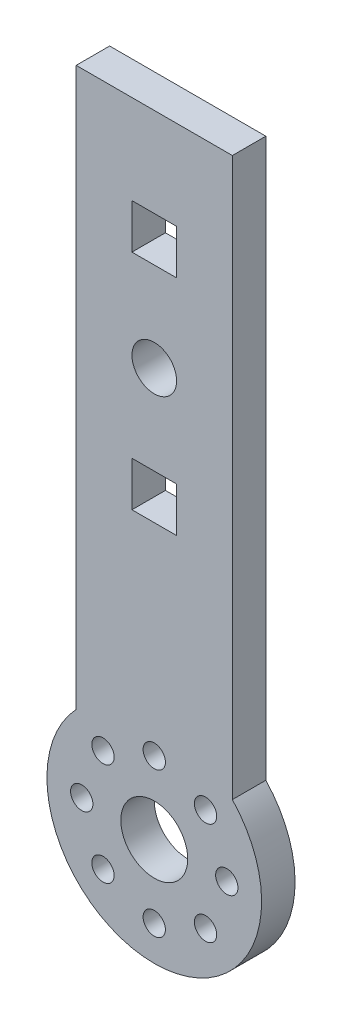
from build123d import *

# Parameters (mm, degrees)
SKETCH_1_W               = 14
SKETCH_1_H               = 13.200286042
EXTRUDE_1_DEPTH          = 3
SKETCH_3_OUTSIDE_W       = 35.048
SKETCH_3_OUTSIDE_H       = 82.027
CUT_EXTRUDE_2_DEPTH      = 3
SKETCH_4_R               = 3
CUT_EXTRUDE_3_DEPTH      = 10
SKETCH_5_R               = 1
CUT_EXTRUDE_4_DEPTH      = 10
SKETCH_6_W               = 4
SKETCH_6_H               = 4
EXTRUDE_3_DEPTH          = 3
CUT_EXTRUDE_5_DEPTH      = 10
PATTERN_CIRCULAR_1_COUNT = 8


with BuildPart() as part:
    # 草图1 → 凸台-拉伸1 (new body)
    with BuildSketch(Plane.XY):
        Rectangle(SKETCH_1_W, SKETCH_1_H)
        with BuildLine():
            ThreePointArc((-7, 6.600143021), (-9.620908892, 0), (-7, -6.600143021))
            Line((-7, -6.600143021), (-7, 6.600143021))
        make_face()
        with BuildLine():
            Line((7, -6.600143021), (-7, -6.600143021))
            ThreePointArc((-7, -6.600143021), (0, -9.620908892), (7, -6.600143021))
        make_face()
        with BuildLine():
            Line((7, 6.600143021), (7, -6.600143021))
            ThreePointArc((7, -6.600143021), (8.941707056, -3.550741166), (9.620908892, 0))
            ThreePointArc((9.620908892, 0), (8.941707056, 3.550741166), (7, 6.600143021))
        make_face()
        with BuildLine():
            ThreePointArc((7, 6.600143021), (0, 9.620908892), (-7, 6.600143021))
            Line((-7, 6.600143021), (7, 6.600143021))
        make_face()
        with BuildLine():
            Line((-7, 56.600143021), (-7, 6.600143021))
            ThreePointArc((-7, 6.600143021), (0, 9.620908892), (7, 6.600143021))
            Line((7, 6.600143021), (7, 56.600143021))
            Line((7, 56.600143021), (-7, 56.600143021))
        make_face()
    extrude(amount=EXTRUDE_1_DEPTH)

    # 草图3 outside → 切除-拉伸2 (cut)
    with BuildSketch(Plane.XY.offset(3)):
        with Locations((0, 23.4895)):
            Rectangle(SKETCH_3_OUTSIDE_W, SKETCH_3_OUTSIDE_H)
        with BuildLine():
            Line((7, 56.600143021), (0, 56.600143021))
            Line((0, 56.600143021), (-7, 56.600143021))
            Line((-7, 56.600143021), (-7, 6.600143021))
            ThreePointArc((-7, 6.600143021), (0, -9.620908892), (7, 6.600143021))
            Line((7, 6.600143021), (7, 56.600143021))
        make_face(mode=Mode.SUBTRACT)
        Polygon((-2, 28.600143021), (0, 28.600143021), (2, 28.600143021), (2, 24.600143021), (-2, 24.600143021), align=None)
        Polygon((-2, 38.600143021), (0, 38.600143021), (2, 38.600143021), (2, 34.600143021), (0, 34.600143021), (-2, 34.600143021), align=None)
        Polygon((-2, 48.600143021), (0, 48.600143021), (2, 48.600143021), (2, 44.600143021), (0, 44.600143021), (-2, 44.600143021), align=None)
    extrude(amount=-CUT_EXTRUDE_2_DEPTH, mode=Mode.SUBTRACT)

    # 草图4 → 切除-拉伸3 (cut)
    with BuildSketch(Plane.XY.offset(3)):
        Circle(SKETCH_4_R)
    extrude(amount=-CUT_EXTRUDE_3_DEPTH, mode=Mode.SUBTRACT)

    # 草图5 → 切除-拉伸4 (cut)
    with BuildSketch(Plane(origin=(0, 0, 0), x_dir=(-1, 0, 0), z_dir=(0, 0, -1))):
        with Locations((0, 6.5)):
            Circle(SKETCH_5_R)
    cut_extrude_4 = extrude(amount=-CUT_EXTRUDE_4_DEPTH, mode=Mode.SUBTRACT)

    # 草图6 → 凸台-拉伸3 (add)
    with BuildSketch(Plane(origin=(0, 0, 0), x_dir=(-1, 0, 0), z_dir=(0, 0, -1))):
        with Locations((0, 36.600143021)):
            Rectangle(SKETCH_6_W, SKETCH_6_H)
    extrude(amount=-EXTRUDE_3_DEPTH)

    # 草图7 → 切除-拉伸5 (cut)
    with BuildSketch(Plane(origin=(0, 0, 0), x_dir=(-1, 0, 0), z_dir=(0, 0, -1))):
        with BuildLine():
            ThreePointArc((0, 38.600143021), (-2, 36.600143021), (0, 34.600143021))
            Line((0, 34.600143021), (0, 38.600143021))
        make_face()
        with BuildLine():
            Line((0, 38.600143021), (0, 34.600143021))
            ThreePointArc((0, 34.600143021), (1.414213562, 35.185929459), (2, 36.600143021))
            ThreePointArc((2, 36.600143021), (1.414213562, 38.014356584), (0, 38.600143021))
        make_face()
    extrude(amount=-CUT_EXTRUDE_5_DEPTH, mode=Mode.SUBTRACT)

    # 阵列(圆周)1: 切除-拉伸4 ×8 about axis
    pattern_circular_1_axis = Axis((0, 0, 0), (0, 0, 1))
    for i in range(1, PATTERN_CIRCULAR_1_COUNT):
        add(cut_extrude_4.rotate(pattern_circular_1_axis, i * 360 / PATTERN_CIRCULAR_1_COUNT), mode=Mode.SUBTRACT)


solid = part.part
